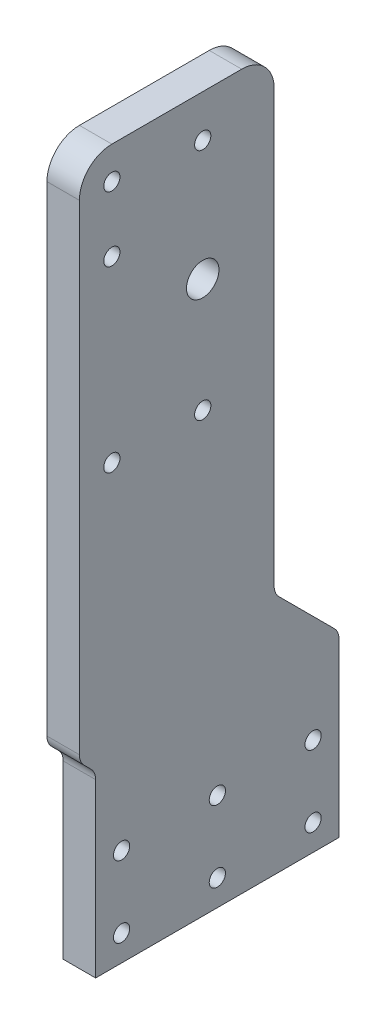
from build123d import *

# Parameters (mm, degrees)
SKETCH1_R           = 2.5
SKETCH1_R_2         = 5
BOSS_EXTRUDE1_DEPTH = 10


with BuildPart() as part:
    # Sketch1 → Boss-Extrude1 (new body)
    with BuildSketch(Plane(origin=(0, 0, 0), x_dir=(0, 0, -1), z_dir=(1, 0, 0))):
        with BuildLine():
            Line((0, 0), (75, 0))
            Line((75, 0), (75, 52.928932188))
            ThreePointArc((75, 52.928932188), (74.619397663, 54.84234935), (73.535533906, 56.464466094))
            Line((73.535533906, 56.464466094), (56.464466094, 73.535533906))
            ThreePointArc((56.464466094, 73.535533906), (55.380602337, 75.15765065), (55, 77.071067812))
            Line((55, 77.071067812), (55, 210))
            ThreePointArc((55, 210), (52.071067812, 217.071067812), (45, 220))
            Line((45, 220), (5, 220))
            ThreePointArc((5, 220), (-2.071067812, 217.071067812), (-5, 210))
            Line((-5, 210), (-5, 62.071067812))
            ThreePointArc((-5, 62.071067812), (-4.619397663, 60.15765065), (-3.535533906, 58.535533906))
            Line((-3.535533906, 58.535533906), (-1.464466094, 56.464466094))
            ThreePointArc((-1.464466094, 56.464466094), (-0.380602337, 54.84234935), (0, 52.928932188))
            Line((0, 52.928932188), (0, 0))
        make_face()
        with Locations((5, 210)):
            Circle(SKETCH1_R, mode=Mode.SUBTRACT)
        with Locations((5, 190)):
            Circle(SKETCH1_R, mode=Mode.SUBTRACT)
        with Locations((33, 207)):
            Circle(SKETCH1_R, mode=Mode.SUBTRACT)
        with Locations((5, 135)):
            Circle(SKETCH1_R, mode=Mode.SUBTRACT)
        with Locations((33, 135)):
            Circle(SKETCH1_R, mode=Mode.SUBTRACT)
        with Locations((8, 30)):
            Circle(SKETCH1_R, mode=Mode.SUBTRACT)
        with Locations((8, 8)):
            Circle(SKETCH1_R, mode=Mode.SUBTRACT)
        with Locations((37.5, 8)):
            Circle(SKETCH1_R, mode=Mode.SUBTRACT)
        with Locations((37.5, 30)):
            Circle(SKETCH1_R, mode=Mode.SUBTRACT)
        with Locations((67, 30)):
            Circle(SKETCH1_R, mode=Mode.SUBTRACT)
        with Locations((67, 8)):
            Circle(SKETCH1_R, mode=Mode.SUBTRACT)
        with Locations((33, 170)):
            Circle(SKETCH1_R_2, mode=Mode.SUBTRACT)
    extrude(amount=BOSS_EXTRUDE1_DEPTH)


solid = part.part
